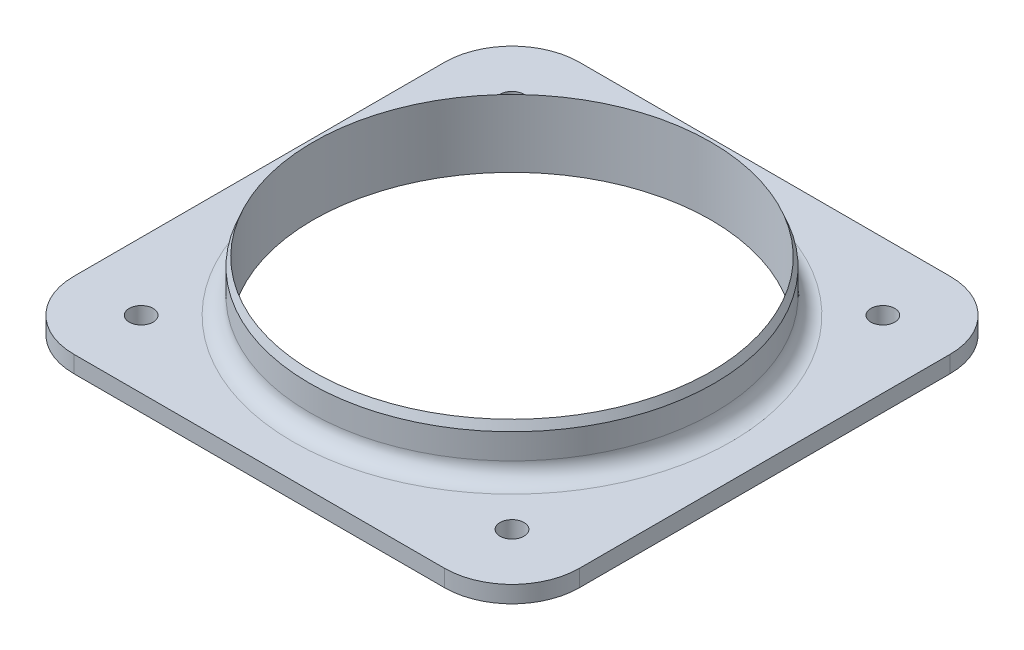
from build123d import *

# Parameters (mm, degrees)
SKETCH1_W           = 95.25
SKETCH1_H           = 95.25
SKETCH1_R           = 37.465
BOSS_EXTRUDE1_DEPTH = 3.175
SKETCH2_R           = 2.25
CUT_EXTRUDE1_DEPTH  = 4.175
CIRPATTERN1_COUNT   = 4
FILLET1_R           = 12.7
FILLET2_R           = 3.175


with BuildPart() as part:
    # Sketch1 → Boss-Extrude1 (new body)
    with BuildSketch(Plane(origin=(0, 0, 0), x_dir=(1, 0, 0), z_dir=(0, 1, 0))):
        Rectangle(SKETCH1_W, SKETCH1_H)
        Circle(SKETCH1_R, mode=Mode.SUBTRACT)
    extrude(amount=BOSS_EXTRUDE1_DEPTH)

    # Sketch2 → Cut-Extrude1 (cut, through all)
    with BuildSketch(Plane(origin=(0, 3.175, 0), x_dir=(1, 0, 0), z_dir=(0, 1, 0))):
        with Locations((-34.925, 34.925)):
            Circle(SKETCH2_R)
    cut_extrude1 = extrude(amount=-CUT_EXTRUDE1_DEPTH, mode=Mode.SUBTRACT)

    # CirPattern1: Cut-Extrude1 ×4 about axis
    cirpattern1_axis = Axis((0, 0, 0), (0, 1, 0))
    for i in range(1, CIRPATTERN1_COUNT):
        add(cut_extrude1.rotate(cirpattern1_axis, i * 360 / CIRPATTERN1_COUNT), mode=Mode.SUBTRACT)

    # Fillet1
    fillet1_edges = [part.edges().sort_by_distance(p)[0] for p in [
        (-47.625, 1.5875, -47.625),
        (47.625, 1.5875, -47.625),
        (47.625, 1.5875, 47.625),
        (-47.625, 1.5875, 47.625),
    ]]
    fillet(fillet1_edges, radius=FILLET1_R)

    # Sketch4 → Revolve1 (revolve)
    with BuildSketch(Plane.XY):
        Polygon((37.465, 9.525), (37.465, 3.175), (38.1, 3.175), (38.1, 10.3505), (38.1, 11.1125), (37.465, 12.7), align=None)
    revolve(axis=Axis((0, 0, 0), (0, 1, 0)))

    # Fillet2
    fillet2_edges = [part.edges().sort_by_distance(p)[0] for p in [
        (-38.1, 3.175, 0),
    ]]
    fillet(fillet2_edges, radius=FILLET2_R)


solid = part.part
